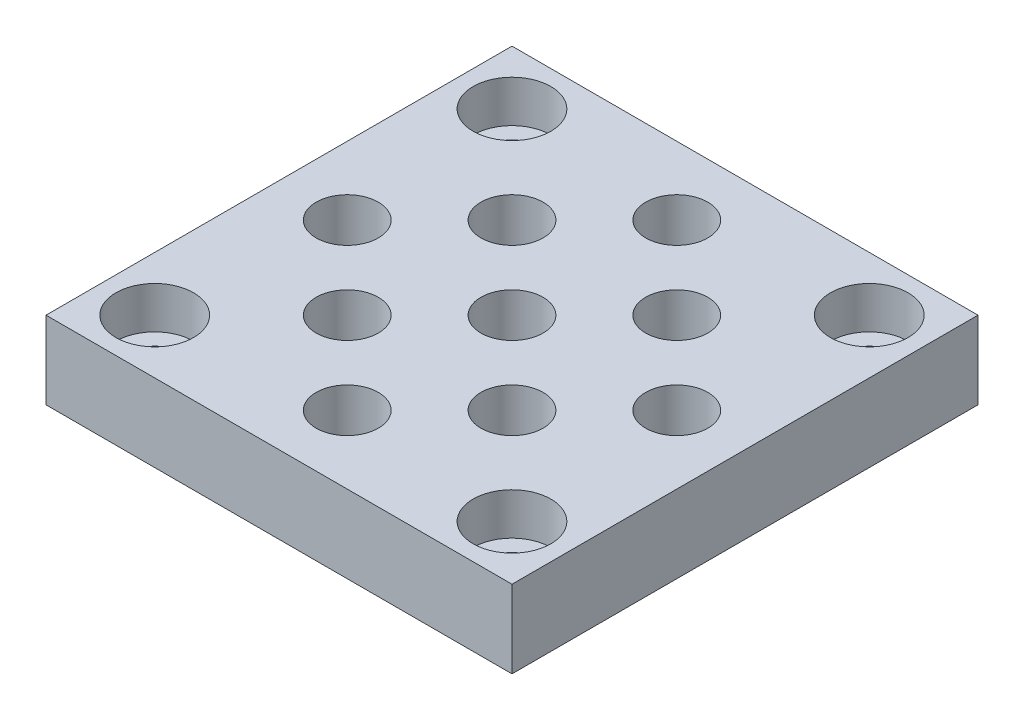
from build123d import *

# Parameters (mm, degrees)
CROQUIS1_W                                           = 60
CROQUIS1_H                                           = 60
SALIENTE_EXTRUIR1_DEPTH                              = 10
CROQUIS3_R                                           = 4
CORTAR_EXTRUIR2_DEPTH                                = 11
MATRIZL1_COUNT                                       = 3
MATRIZL1_PITCH                                       = 15
MATRIZL1_COUNT_DIR2                                  = 3
MATRIZL1_PITCH_DIR2                                  = 15
REFRENTADO_PARA_TORNILLO_CON_CABEZA_HUEC_D           = 5.5
REFRENTADO_PARA_TORNILLO_CON_CABEZA_HUEC_CBORE_D     = 10
REFRENTADO_PARA_TORNILLO_CON_CABEZA_HUEC_CBORE_DEPTH = 5.4


with BuildPart() as part:
    # Croquis1 → Saliente-Extruir1 (new body)
    with BuildSketch(Plane(origin=(0, 0, 0), x_dir=(1, 0, 0), z_dir=(0, 1, 0))):
        Rectangle(CROQUIS1_W, CROQUIS1_H)
    extrude(amount=SALIENTE_EXTRUIR1_DEPTH)

    # Croquis3 → Cortar-Extruir2 (cut, through all)
    with BuildSketch(Plane(origin=(0, 10, 0), x_dir=(1, 0, 0), z_dir=(0, 1, 0))):
        with Locations((0, -21.213203436)):
            Circle(CROQUIS3_R)
    cortar_extruir2 = extrude(amount=-CORTAR_EXTRUIR2_DEPTH, mode=Mode.SUBTRACT)

    # MatrizL1: Cortar-Extruir2 3 × 3
    with Locations(*[Vector(0.707106781, 0, -0.707106781) * (i * MATRIZL1_PITCH) + Vector(-0.707106781, 0, -0.707106781) * (j * MATRIZL1_PITCH_DIR2) for i in range(MATRIZL1_COUNT) for j in range(MATRIZL1_COUNT_DIR2) if (i, j) != (0, 0)]):
        add(cortar_extruir2, mode=Mode.SUBTRACT)

    # Refrentado para tornillo con cabeza hueca de M51 (through all)
    with Locations(Plane(origin=(-23, 10, -23), x_dir=(0, 0, 1), z_dir=(0, 1, 0))):
        with Locations((0, 0), (0, 46), (46, 46), (46, 0)):
            CounterBoreHole(REFRENTADO_PARA_TORNILLO_CON_CABEZA_HUEC_D / 2, REFRENTADO_PARA_TORNILLO_CON_CABEZA_HUEC_CBORE_D / 2, REFRENTADO_PARA_TORNILLO_CON_CABEZA_HUEC_CBORE_DEPTH)


solid = part.part
